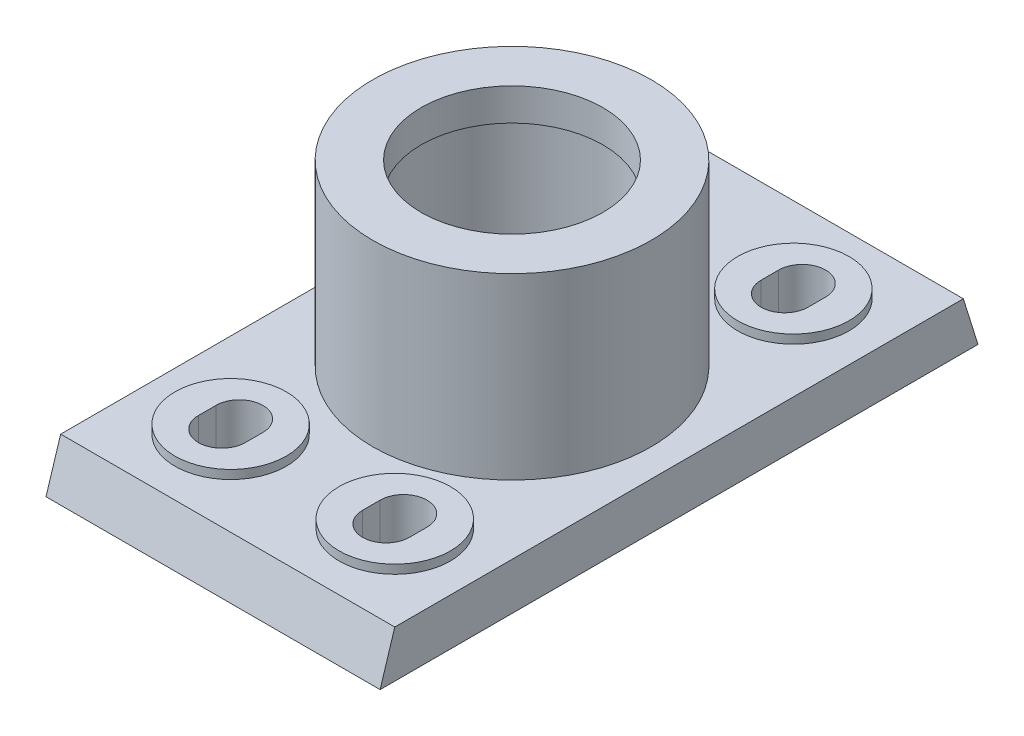
from build123d import *

# Parameters (mm, degrees)
BOSS_EXTRUDE2_DEPTH = 57
SKETCH3_R           = 47.5
SKETCH3_R_2         = 31
BOSS_EXTRUDE3_DEPTH = 13
SKETCH4_R           = 47.5
SKETCH4_R_2         = 32.5
BOSS_EXTRUDE4_DEPTH = 37
SKETCH5_R           = 47.5
SKETCH5_R_2         = 31
BOSS_EXTRUDE5_DEPTH = 11
SKETCH6_W           = 94
SKETCH6_H           = 85.5
CUT_EXTRUDE1_DEPTH  = 3
SKETCH7_R           = 19
BOSS_EXTRUDE6_DEPTH = 3
CUT_EXTRUDE2_DEPTH  = 20
SKETCH9_R           = 1.5
CUT_EXTRUDE3_DEPTH  = 5


with BuildPart() as part:
    # Sketch1 → Boss-Extrude2 (new body, symmetric)
    with BuildSketch(Plane(origin=(0, 0, 0), x_dir=(0, 0, -1), z_dir=(1, 0, 0))):
        Polygon((-102, -16), (102, -16), (97, 0), (-97, 0), align=None)
    extrude(amount=BOSS_EXTRUDE2_DEPTH, both=True)

    # Sketch3 → Boss-Extrude3 (add)
    with BuildSketch(Plane(origin=(0, 0, 0), x_dir=(1, 0, 0), z_dir=(0, 1, 0))):
        with Locations(Location((0, 0, 0), (0, 0, 90))):  # turned: the seam where the file's is
            Circle(SKETCH3_R)
        with Locations(Location((0, 0, 0), (0, 0, 270))):  # turned: the seam where the file's is
            Circle(SKETCH3_R_2, mode=Mode.SUBTRACT)
    extrude(amount=BOSS_EXTRUDE3_DEPTH)

    # Sketch4 → Boss-Extrude4 (add)
    with BuildSketch(Plane(origin=(0, 13, 0), x_dir=(1, 0, 0), z_dir=(0, 1, 0))):
        with Locations(Location((0, 0, 0), (0, 0, 90))):  # turned: the seam where the file's is
            Circle(SKETCH4_R)
        with Locations(Location((0, 0, 0), (0, 0, 270))):  # turned: the seam where the file's is
            Circle(SKETCH4_R_2, mode=Mode.SUBTRACT)
    extrude(amount=BOSS_EXTRUDE4_DEPTH)

    # Sketch5 → Boss-Extrude5 (add)
    with BuildSketch(Plane(origin=(0, 50, 0), x_dir=(1, 0, 0), z_dir=(0, 1, 0))):
        with Locations(Location((0, 0, 0), (0, 0, 90))):  # turned: the seam where the file's is
            Circle(SKETCH5_R)
        with Locations(Location((0, 0, 0), (0, 0, 270))):  # turned: the seam where the file's is
            Circle(SKETCH5_R_2, mode=Mode.SUBTRACT)
    extrude(amount=BOSS_EXTRUDE5_DEPTH)

    # Sketch6 → Cut-Extrude1 (cut)
    with BuildSketch(Plane.XZ.offset(16)):
        with Locations((0, 49.25)):
            Rectangle(SKETCH6_W, SKETCH6_H)
        with Locations((0, -49.25)):
            Rectangle(SKETCH6_W, SKETCH6_H)
    extrude(amount=-CUT_EXTRUDE1_DEPTH, mode=Mode.SUBTRACT)

    # Sketch7 → Boss-Extrude6 (add)
    with BuildSketch(Plane(origin=(0, 0, 0), x_dir=(1, 0, 0), z_dir=(0, 1, 0))):
        with Locations(Location((-28, -68, 0), (0, 0, 90))):  # turned: the seam where the file's is
            Circle(SKETCH7_R)
        with Locations(Location((28, -68, 0), (0, 0, 90))):  # turned: the seam where the file's is
            Circle(SKETCH7_R)
        with Locations(Location((28, 68, 0), (0, 0, 90))):  # turned: the seam where the file's is
            Circle(SKETCH7_R)
        with Locations(Location((-28, 68, 0), (0, 0, 90))):  # turned: the seam where the file's is
            Circle(SKETCH7_R)
    extrude(amount=BOSS_EXTRUDE6_DEPTH)

    # Sketch8 → Cut-Extrude2 (cut, through all)
    with BuildSketch(Plane(origin=(0, 3, 0), x_dir=(1, 0, 0), z_dir=(0, 1, 0))):
        with BuildLine():
            Line((36, -65), (36, -71))
            ThreePointArc((36, -71), (28, -79), (20, -71))
            Line((20, -71), (20, -65))
            ThreePointArc((20, -65), (28, -57), (36, -65))
        make_face()
        with BuildLine():
            Line((-36, -65), (-36, -71))
            ThreePointArc((-36, -71), (-28, -79), (-20, -71))
            Line((-20, -71), (-20, -65))
            ThreePointArc((-20, -65), (-28, -57), (-36, -65))
        make_face()
        with BuildLine():
            Line((36, 65), (36, 71))
            ThreePointArc((36, 71), (28, 79), (20, 71))
            Line((20, 71), (20, 65))
            ThreePointArc((20, 65), (28, 57), (36, 65))
        make_face()
        with BuildLine():
            Line((-36, 65), (-36, 71))
            ThreePointArc((-36, 71), (-28, 79), (-20, 71))
            Line((-20, 71), (-20, 65))
            ThreePointArc((-20, 65), (-28, 57), (-36, 65))
        make_face()
    extrude(amount=-CUT_EXTRUDE2_DEPTH, mode=Mode.SUBTRACT)

    # Sketch9 → Cut-Extrude3 (cut)
    with BuildSketch(Plane(origin=(0, 0, 0), x_dir=(1, 0, 0), z_dir=(0, 1, 0))):
        with Locations(Location((-22, 0, 0), (0, 0, 270))):  # turned: the seam where the file's is
            Circle(SKETCH9_R)
    extrude(amount=-CUT_EXTRUDE3_DEPTH, mode=Mode.SUBTRACT)


solid = part.part
